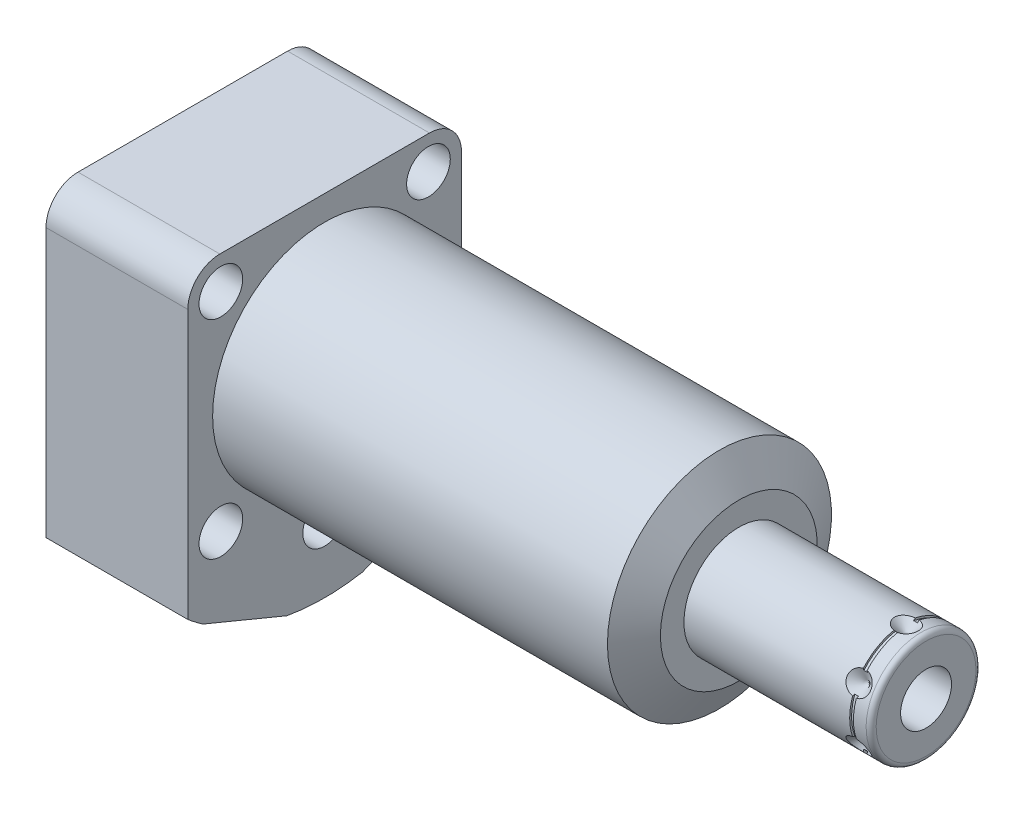
from build123d import *

# Parameters (mm, degrees)
EXTRUDE1_DEPTH           = 83.82
EXTRUDE1_DEPTH_BACK      = 28.702
CUT_EXTRUDE1_REACH       = 100.269
SKETCH2_R                = 22.6695
SKETCH11_W               = 0.762
SKETCH11_H               = 0.381
SKETCH15_R               = 2.7432
EXTRUDE3_DEPTH           = 2.9972
CUT_EXTRUDE2_DEPTH       = 2.54
CHAMFER1_SIZE            = 0.381
CHAMFER1_OF_MIRROR2_SIZE = 0.381
SKETCH21_R               = 0.889
FILLET1_R                = 6.477
SKETCH22_W               = 4.4196
SKETCH22_H               = 28.702
HOLE1_AT_2_COUNT         = 2
HOLE1_AT_2_PITCH         = 54.877785999
HOLE1_AT_3_COUNT         = 2
HOLE1_AT_3_PITCH         = 54.877785999
HOLE1_AT_4_COUNT         = 2
HOLE1_AT_4_PITCH         = 22.73112685
HOLE1_AT_5_COUNT         = 2
HOLE1_AT_5_PITCH         = 22.73112685
CIRPATTERN1_COUNT        = 6


with BuildPart() as part:
    # Sketch1 → Extrude1 (new, two sides)
    with BuildSketch(Plane(origin=(0, 0, 0), x_dir=(0, 0, -1), z_dir=(1, 0, 0))) as extrude1_sk:
        with BuildLine():
            Line((-27.686, 27.686), (-27.686, -33.136049915))
            ThreePointArc((-27.686, -33.136049915), (-26.189365587, -34.331174319), (-24.641206283, -35.458755659))
            Line((-24.641206283, -35.458755659), (-7.649162519, -42.497090639))
            ThreePointArc((-7.649162519, -42.497090639), (0, -43.18), (7.649162519, -42.497090639))
            Line((7.649162519, -42.497090639), (24.641206283, -35.458755659))
            ThreePointArc((24.641206283, -35.458755659), (26.189365587, -34.331174319), (27.686, -33.136049915))
            Line((27.686, -33.136049915), (27.686, 27.686))
            Line((27.686, 27.686), (-27.686, 27.686))
        make_face()
    extrude(amount=EXTRUDE1_DEPTH)
    extrude(extrude1_sk.sketch, amount=-EXTRUDE1_DEPTH_BACK)

    # Sketch2 → Cut-Extrude1 (cut, up to next)
    with BuildSketch(Plane(origin=(0, 0, 0), x_dir=(0, 0, -1), z_dir=(1, 0, 0)), mode=Mode.PRIVATE) as cut_extrude1_sk1:
        with BuildLine():
            Line((27.686, 27.686), (-27.686, 27.686))
            Line((-27.686, 27.686), (-27.686, -33.136049915))
            ThreePointArc((-27.686, -33.136049915), (-26.189365587, -34.331174319), (-24.641206283, -35.458755659))
            Line((-24.641206283, -35.458755659), (-7.649162519, -42.497090639))
            ThreePointArc((-7.649162519, -42.497090639), (0, -43.18), (7.649162519, -42.497090639))
            Line((7.649162519, -42.497090639), (24.641206283, -35.458755659))
            ThreePointArc((24.641206283, -35.458755659), (26.189365587, -34.331174319), (27.686, -33.136049915))
            Line((27.686, -33.136049915), (27.686, 27.686))
        make_face()
        Circle(SKETCH2_R, mode=Mode.SUBTRACT)
    cut_extrude1_tool1 = extrude(cut_extrude1_sk1.sketch, amount=CUT_EXTRUDE1_REACH, mode=Mode.PRIVATE) & part.part
    add(cut_extrude1_tool1.solids().sort_by_distance((0, -33.616138, -25.643904))[0], mode=Mode.SUBTRACT)

    # Sketch3 → Cut-Revolve1 (revolve, cut)
    with BuildSketch(Plane.XY, mode=Mode.PRIVATE) as cut_revolve1_sk:
        Polygon((79.897193596, 22.6695), (83.82, 15.875), (83.82, 22.6695), align=None)
    revolve(cut_revolve1_sk.sketch.rotate(Axis((23.304450239, 0, 0), (1, 0, 0)), 90), axis=Axis((23.304450239, 0, 0), (1, 0, 0)), mode=Mode.SUBTRACT)

    # S2D0002 → Cut-Revolve2 (revolve, cut)
    with BuildSketch(Plane(origin=(-24.9936, -18.1864, 11.8618), x_dir=(0, 1, 0), z_dir=(0, 0, 1)), mode=Mode.PRIVATE) as cut_revolve2_sk:
        Polygon((-7.1374, 2.2606), (-4.6863, 2.2606), (-4.6863, 3.7084), (-10.3886, 3.7084), (-10.3886, -9.7282), (-9.144, -9.7282), (-9.144, -0.7366), (-7.1374, -0.7366), align=None)
    cut_revolve2 = revolve(cut_revolve2_sk.sketch.rotate(Axis((-1.435104963, -28.575, 11.8618), (-1, 0, 0)), 90), axis=Axis((-1.435104963, -28.575, 11.8618), (-1, 0, 0)), mode=Mode.SUBTRACT)

    # Sketch6 → Cut-Revolve4 (revolve, cut)
    with BuildSketch(Plane(origin=(-12.192, 0, 0), x_dir=(0, 0, -1), z_dir=(1, 0, 0)), mode=Mode.PRIVATE) as cut_revolve4_sk:
        Polygon((-22.196216323, -36.196576042), (-25.979687784, -34.62941085), (-26.076889376, -34.864076251), (-16.145184401, -38.977923149), (-10.624133986, -25.648928357), (-16.115304375, -23.374411109), (-21.218387946, -35.694344675), (-22.147615527, -36.079243341), align=None)
    cut_revolve4 = revolve(cut_revolve4_sk.sketch.rotate(Axis((-12.192, -11.999068119, 4.970176751), (0, 0.9238795325112866, -0.38268343236509017)), 180), axis=Axis((-12.192, -11.999068119, 4.970176751), (0, 0.9238795325112866, -0.38268343236509017)), mode=Mode.SUBTRACT)

    # Mirror1: Cut-Revolve2, Cut-Revolve4 across plane
    add(cut_revolve2.mirror(Plane.XY), mode=Mode.SUBTRACT)
    add(cut_revolve4.mirror(Plane.XY), mode=Mode.SUBTRACT)

    # Sketch7 → Revolve1 (revolve)
    with BuildSketch(Plane.XY, mode=Mode.PRIVATE) as revolve1_sk:
        with BuildLine():
            Line((83.82, 0), (83.82, 11.1125))
            Line((83.82, 11.1125), (120.688, 11.1125))
            ThreePointArc((120.688, 11.1125), (121.40642049, 10.81492049), (121.704, 10.0965))
            Line((121.704, 10.0965), (121.704, 0))
            Line((121.704, 0), (83.82, 0))
        make_face()
    revolve(revolve1_sk.sketch.rotate(Axis((4.993122661, 0, 0), (1, 0, 0)), 180), axis=Axis((4.993122661, 0, 0), (1, 0, 0)))

    # S2D0001 → Cut-Revolve8 (revolve, cut)
    with BuildSketch(Plane.XY, mode=Mode.PRIVATE) as cut_revolve8_sk:
        Polygon((121.704, -5.1562), (104.686, -5.1562), (101.587842476, 0), (121.704, 0), align=None)
    revolve(cut_revolve8_sk.sketch.rotate(Axis((-2.5273, 0, 0), (-1, 0, 0)), 180), axis=Axis((-2.5273, 0, 0), (-1, 0, 0)), mode=Mode.SUBTRACT)

    # Sketch9 → Cut-Revolve9 (revolve, cut)
    with BuildSketch(Plane.XY, mode=Mode.PRIVATE) as cut_revolve9_sk:
        Polygon((117.7416, -11.1125), (115.3286, -11.1125), (117.7416, -8.6995), align=None)
    cut_revolve9 = revolve(cut_revolve9_sk.sketch.rotate(Axis((117.7416, -6.253416753, 0), (0, 1, 0)), 270), axis=Axis((117.7416, -6.253416753, 0), (0, 1, 0)), mode=Mode.SUBTRACT)

    # Sketch11 → Cut-Revolve5 (revolve, cut)
    with BuildSketch(Plane(origin=(0, 0, 0), x_dir=(1, 0, 0), z_dir=(0, 1, 0)), mode=Mode.PRIVATE) as cut_revolve5_sk:
        with Locations((117.7416, -10.922)):
            Rectangle(SKETCH11_W, SKETCH11_H)
    revolve(cut_revolve5_sk.sketch.rotate(Axis((0, 0, 0), (1, 0, 0)), 90), axis=Axis((0, 0, 0), (1, 0, 0)), mode=Mode.SUBTRACT)

    # Sketch15 → Extrude3 (add)
    with BuildSketch(Plane.ZY.offset(24.257)):
        with Locations(Location((11.8618, -28.575, 0), (0, 0, 180))):
            Circle(SKETCH15_R)
    extrude3 = extrude(amount=EXTRUDE3_DEPTH)

    # Sketch16 → Cut-Extrude2 (cut)
    with BuildSketch(Plane.ZY.offset(27.2542)):
        Polygon((13.29894029, -28.575), (12.580370145, -27.3304), (11.143229855, -27.3304), (10.42465971, -28.575), (11.143229855, -29.8196), (12.580370145, -29.8196), align=None)
    cut_extrude2 = extrude(amount=-CUT_EXTRUDE2_DEPTH, mode=Mode.SUBTRACT)

    # Chamfer1
    chamfer1_edges = [part.edges().sort_by_distance(p)[0] for p in [
        (-27.2542, -28.575, 14.605),
    ]]
    chamfer(chamfer1_edges, length=CHAMFER1_SIZE)

    # Mirror2: Extrude3, Cut-Extrude2 across plane
    add(extrude3.mirror(Plane.XY))
    add(cut_extrude2.mirror(Plane.XY), mode=Mode.SUBTRACT)

    # Chamfer1 of Mirror2
    chamfer1_of_mirror2_edges = [part.edges().sort_by_distance(p)[0] for p in [
        (-27.2542, -28.575, -14.605),
    ]]
    chamfer(chamfer1_of_mirror2_edges, length=CHAMFER1_OF_MIRROR2_SIZE)

    # Fillet1
    fillet1_edges = [part.edges().sort_by_distance(p)[0] for p in [
        (-14.351, 27.686, -27.686),
        (-14.351, 27.686, 27.686),
    ]]
    fillet(fillet1_edges, radius=FILLET1_R)

    # Sketch22 → Hole1 (revolve, cut)
    with BuildSketch(Plane(origin=(0, -29.6926, 0), x_dir=(0, 0, -1), z_dir=(0, 1, 0))):
        with Locations((2.2098, 14.351)):
            Rectangle(SKETCH22_W, SKETCH22_H)
    hole1 = revolve(axis=Axis((-110, -29.6926, 0), (1, 0, 0)), mode=Mode.SUBTRACT)

    # Hole1 at 2: Hole1 ×2
    with Locations(*[Vector(0, 0.9238419348863701, 0.3827741884524189) * (i * HOLE1_AT_2_PITCH) for i in range(1, HOLE1_AT_2_COUNT)]):
        add(hole1, mode=Mode.SUBTRACT)

    # Hole1 at 3: Hole1 ×2
    with Locations(*[Vector(0, 0.9238419348863701, -0.3827741884524189) * (i * HOLE1_AT_3_PITCH) for i in range(1, HOLE1_AT_3_COUNT)]):
        add(hole1, mode=Mode.SUBTRACT)

    # Hole1 at 4: Hole1 ×2
    with Locations(*[Vector(0, 0.3821543937194909, 0.9240984900760786) * (i * HOLE1_AT_4_PITCH) for i in range(1, HOLE1_AT_4_COUNT)]):
        add(hole1, mode=Mode.SUBTRACT)

    # Hole1 at 5: Hole1 ×2
    with Locations(*[Vector(0, 0.38215439371949145, -0.9240984900760785) * (i * HOLE1_AT_5_PITCH) for i in range(1, HOLE1_AT_5_COUNT)]):
        add(hole1, mode=Mode.SUBTRACT)

    # CirPattern1: Cut-Revolve9 ×6 about axis
    cirpattern1_axis = Axis((83.821, 0, 0), (-1, 0, 0))
    for i in range(1, CIRPATTERN1_COUNT):
        add(cut_revolve9.rotate(cirpattern1_axis, i * 360 / CIRPATTERN1_COUNT), mode=Mode.SUBTRACT)


with BuildPart() as body_2:
    # Sketch21 → Revolve4 (revolve)
    with BuildSketch(Plane.XY.offset(11.8618), mode=Mode.PRIVATE) as revolve4_sk:
        with Locations((-28.1178, -23.7617)):
            Circle(SKETCH21_R)
    revolve(revolve4_sk.sketch.rotate(Axis((-35.974373203, -28.575, 11.8618), (1, 0, 0)), 90), axis=Axis((-35.974373203, -28.575, 11.8618), (1, 0, 0)))


with BuildPart() as body_3:
    # Mirror3: mirrored copy
    add(body_2.part.mirror(Plane.XY))


solid = Compound([part.part, body_2.part, body_3.part])
